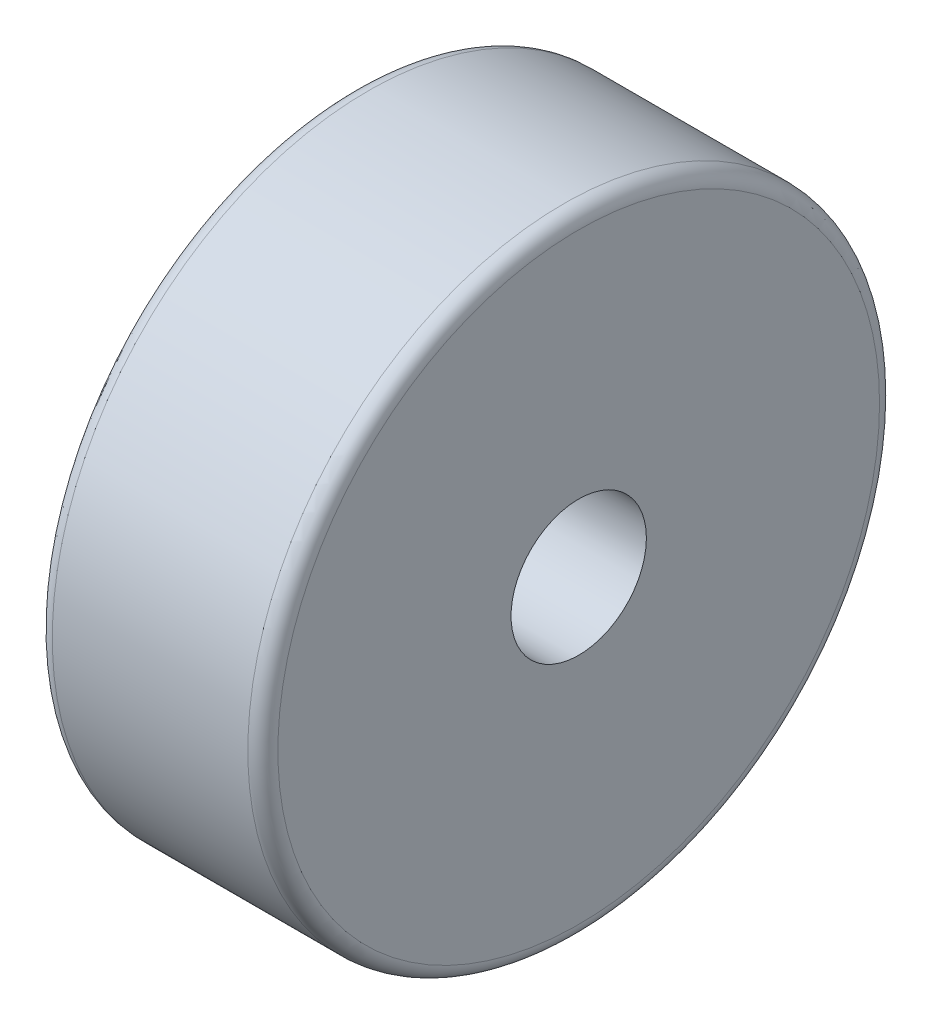
from build123d import *

# Parameters (mm, degrees)
SKETCH1_R           = 21
BOSS_EXTRUDE1_DEPTH = 15
FILLET1_R           = 1
SKETCH2_R           = 4.5
CUT_EXTRUDE1_DEPTH  = 15


with BuildPart() as part:
    # Sketch1 → Boss-Extrude1 (new body)
    with BuildSketch(Plane(origin=(0, 0, 0), x_dir=(0, 0, -1), z_dir=(1, 0, 0))):
        Circle(SKETCH1_R)
    extrude(amount=-BOSS_EXTRUDE1_DEPTH)

    # Fillet1
    fillet1_edges = [part.edges().sort_by_distance(p)[0] for p in [
        (0, 0, 21),
        (-15, 0, 21),
    ]]
    fillet(fillet1_edges, radius=FILLET1_R)

    # Sketch2 → Cut-Extrude1 (cut)
    with BuildSketch(Plane(origin=(0, 0, 0), x_dir=(0, 0, -1), z_dir=(1, 0, 0))):
        Circle(SKETCH2_R)
    extrude(amount=-CUT_EXTRUDE1_DEPTH, mode=Mode.SUBTRACT)


solid = part.part
